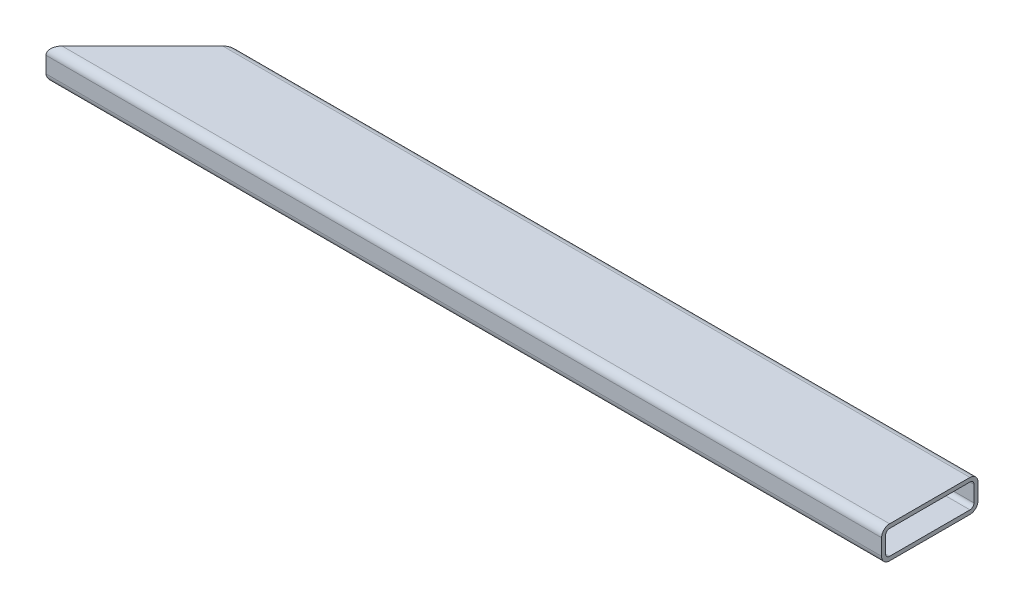
from build123d import *

# Parameters (mm, degrees)
SKETCH1_W           = 76.2
SKETCH1_H           = 25.4
BOSS_EXTRUDE1_DEPTH = 660.4
FILLET1_R           = 6.35
SHELL1_T            = -3.175
CUT_EXTRUDE1_DEPTH  = 25.4


with BuildPart() as part:
    # Sketch1 → Boss-Extrude1 (new body)
    with BuildSketch(Plane(origin=(0, 0, 0), x_dir=(0, 0, -1), z_dir=(1, 0, 0))):
        with Locations((38.1, 12.7)):
            Rectangle(SKETCH1_W, SKETCH1_H)
    extrude(amount=BOSS_EXTRUDE1_DEPTH)

    # Fillet1
    fillet1_edges = [part.edges().sort_by_distance(p)[0] for p in [
        (330.2, 25.4, 0),
        (330.2, 25.4, -76.2),
        (330.2, 0, -76.2),
        (330.2, 0, 0),
    ]]
    fillet(fillet1_edges, radius=FILLET1_R)

    # Shell1
    shell1_openings = [part.faces().sort_by_distance(p)[0] for p in [
        (660.4, 12.7, -38.1),
        (0, 12.7, -38.1),
    ]]
    offset(amount=SHELL1_T, openings=shell1_openings, kind=Kind.INTERSECTION)

    # Sketch2 → Cut-Extrude1 (cut)
    with BuildSketch(Plane(origin=(0, 25.4, 0), x_dir=(1, 0, 0), z_dir=(0, 1, 0))):
        Polygon((0, 0), (76.2, 76.2), (0, 76.2), align=None)
    extrude(amount=-CUT_EXTRUDE1_DEPTH, mode=Mode.SUBTRACT)


solid = part.part
